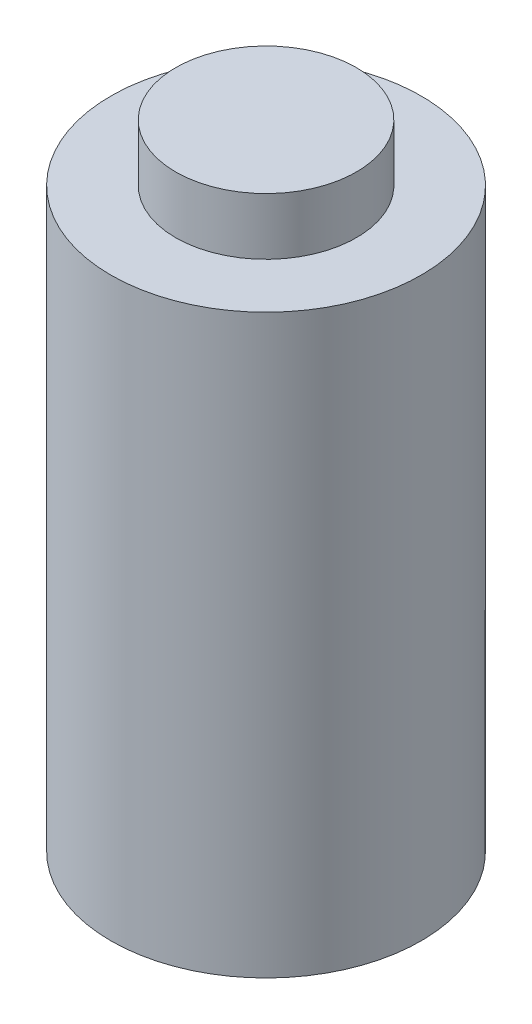
from build123d import *

# Parameters (mm, degrees)
SKETCH1_R           = 21.8
SKETCH1_R_2         = 16.8
BOSS_EXTRUDE1_DEPTH = 80
SKETCH3_R           = 21.8
BOSS_EXTRUDE2_DEPTH = 1
SKETCH4_R           = 12.7
BOSS_EXTRUDE3_DEPTH = 8


with BuildPart() as part:
    # Sketch1 → Boss-Extrude1 (new body)
    with BuildSketch(Plane(origin=(0, 0, 0), x_dir=(1, 0, 0), z_dir=(0, 1, 0))):
        Circle(SKETCH1_R)
        Circle(SKETCH1_R_2, mode=Mode.SUBTRACT)
    extrude(amount=BOSS_EXTRUDE1_DEPTH)

    # Sketch3 → Boss-Extrude2 (add)
    with BuildSketch(Plane(origin=(0, 80, 0), x_dir=(1, 0, 0), z_dir=(0, 1, 0))):
        Circle(SKETCH3_R)
    extrude(amount=BOSS_EXTRUDE2_DEPTH)

    # Sketch4 → Boss-Extrude3 (add)
    with BuildSketch(Plane(origin=(0, 81, 0), x_dir=(1, 0, 0), z_dir=(0, 1, 0))):
        Circle(SKETCH4_R)
    extrude(amount=BOSS_EXTRUDE3_DEPTH)


solid = part.part
